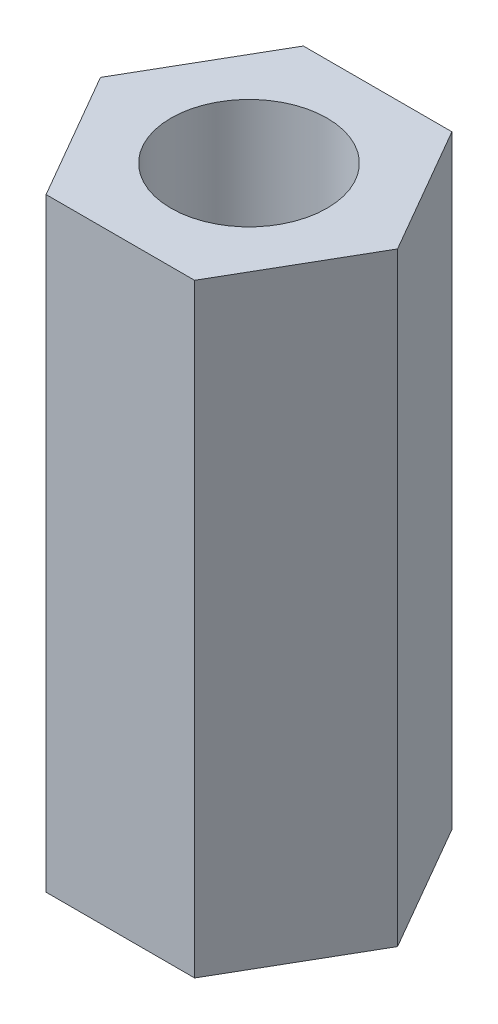
from build123d import *

# Parameters (mm, degrees)
BOSS_EXTRUDE1_DEPTH    = 18.67
F_10_24_TAPPED_HOLE1_D = 4.826


with BuildPart() as part:
    # Sketch1 → Boss-Extrude1 (new body)
    with BuildSketch(Plane(origin=(0, 0, 0), x_dir=(1, 0, 0), z_dir=(0, 1, 0))):
        Polygon((4.58993464, 0), (2.29496732, 3.975), (-2.29496732, 3.975), (-4.58993464, 0), (-2.29496732, -3.975), (2.29496732, -3.975), align=None)
    extrude(amount=BOSS_EXTRUDE1_DEPTH)

    # #10-24 Tapped Hole1 (through all)
    with Locations(Plane(origin=(0, 18.67, 0), x_dir=(-1, 0, 0), z_dir=(0, 1, 0))):
        with Locations((0, 0)):
            Hole(F_10_24_TAPPED_HOLE1_D / 2)


solid = part.part
